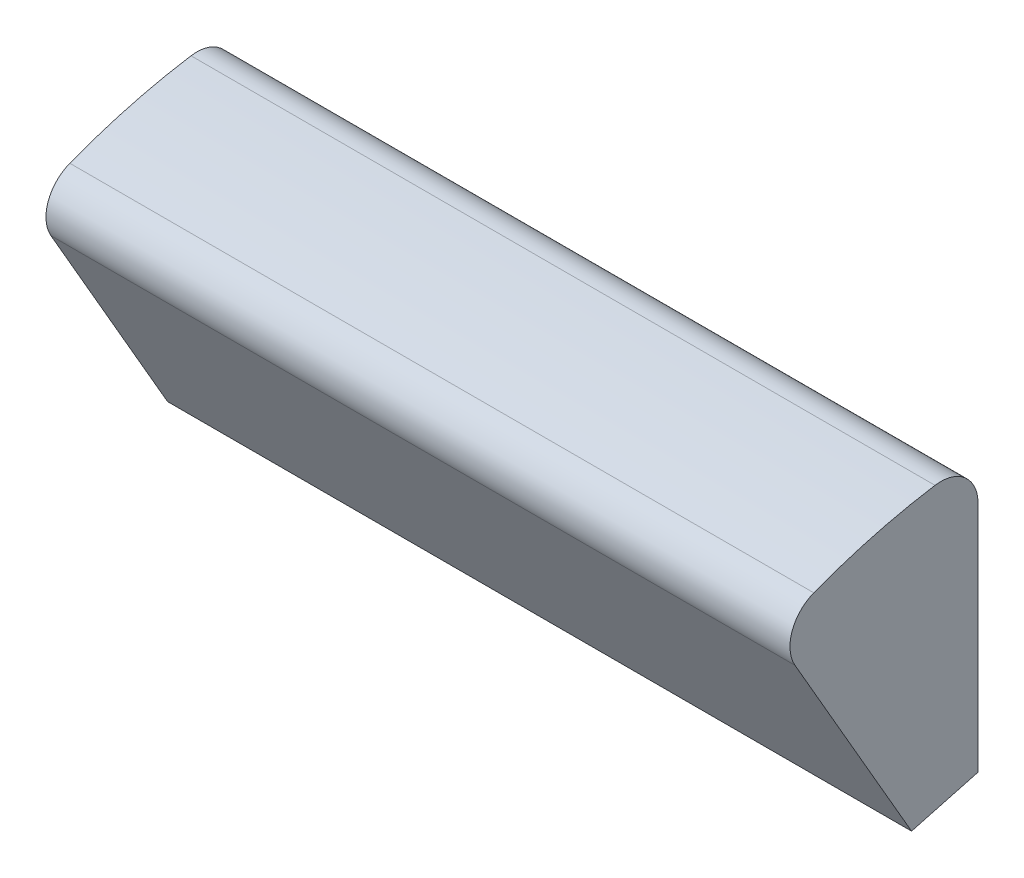
from build123d import *

# Parameters (mm, degrees)
BOSS_EXTRUDE1_DEPTH = 30


with BuildPart() as part:
    # Sketch3 → Boss-Extrude1 (new body)
    with BuildSketch(Plane(origin=(0, 0, 0), x_dir=(0, 0, -1), z_dir=(1, 0, 0))):
        with BuildLine():
            Line((-2, 22.226110771), (-2, 12.821942467))
            Line((-2, 12.821942467), (-4.678920426, 12.104127903))
            Line((-4.678920426, 12.104127903), (-9.381004578, 20.248376555))
            ThreePointArc((-9.381004578, 20.248376555), (-9.496151336, 21.498457721), (-8.620764237, 22.398268325))
            ThreePointArc((-8.620764237, 22.398268325), (-6.211657082, 23.182219831), (-3.733333333, 23.707851489))
            ThreePointArc((-3.733333333, 23.707851489), (-2.525320566, 23.366286196), (-2, 22.226110771))
        make_face()
    extrude(amount=BOSS_EXTRUDE1_DEPTH)


solid = part.part
